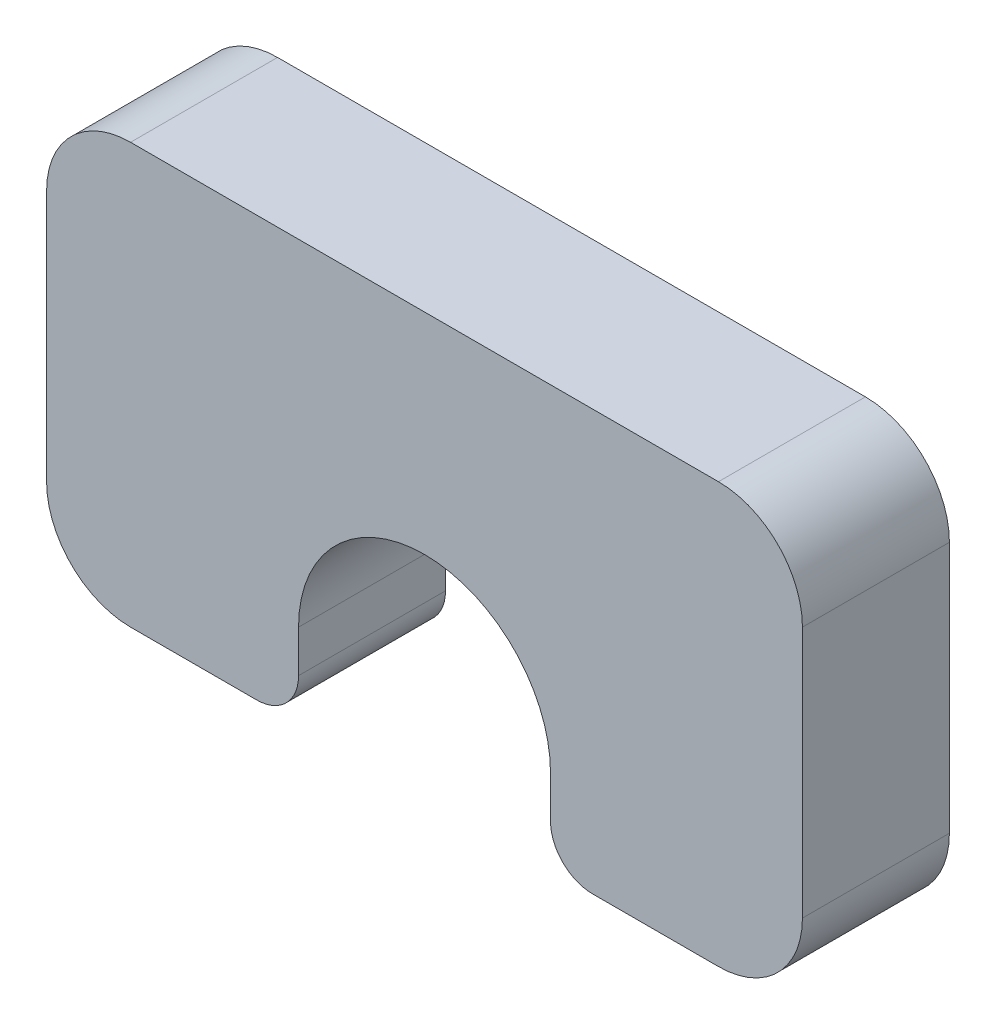
from build123d import *

# Parameters (mm, degrees)
BOSS_EXTRUDE1_DEPTH = 1.75


with BuildPart() as part:
    # Sketch1 → Boss-Extrude1 (new body, symmetric)
    with BuildSketch(Plane.XY):
        with BuildLine():
            Line((2, 0), (5, 0))
            ThreePointArc((5, 0), (5.707106781, 0.292893219), (6, 1))
            Line((6, 1), (6, 2))
            ThreePointArc((6, 2), (9, 5), (12, 2))
            Line((12, 2), (12, 1))
            ThreePointArc((12, 1), (12.292893219, 0.292893219), (13, 0))
            Line((13, 0), (16, 0))
            ThreePointArc((16, 0), (17.414213562, 0.585786438), (18, 2))
            Line((18, 2), (18, 8))
            ThreePointArc((18, 8), (17.414213562, 9.414213562), (16, 10))
            Line((16, 10), (2, 10))
            ThreePointArc((2, 10), (0.585786438, 9.414213562), (0, 8))
            Line((0, 8), (0, 2))
            ThreePointArc((0, 2), (0.585786438, 0.585786438), (2, 0))
        make_face()
    extrude(amount=BOSS_EXTRUDE1_DEPTH, both=True)


solid = part.part
